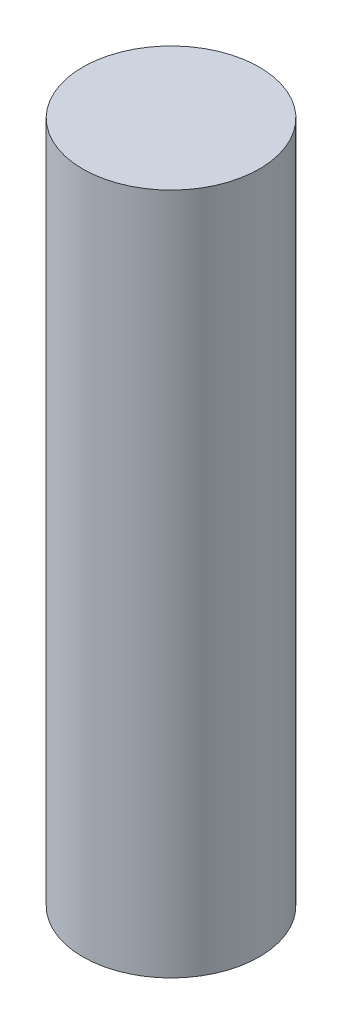
from build123d import *

# Parameters (mm, degrees)
SKETCH3_R           = 11
BOSS_EXTRUDE5_DEPTH = 85


with BuildPart() as part:
    # Sketch3 → Boss-Extrude5 (new body)
    with BuildSketch(Plane(origin=(0, 0, 0), x_dir=(1, 0, 0), z_dir=(0, 1, 0))):
        Circle(SKETCH3_R)
    extrude(amount=BOSS_EXTRUDE5_DEPTH)


solid = part.part
